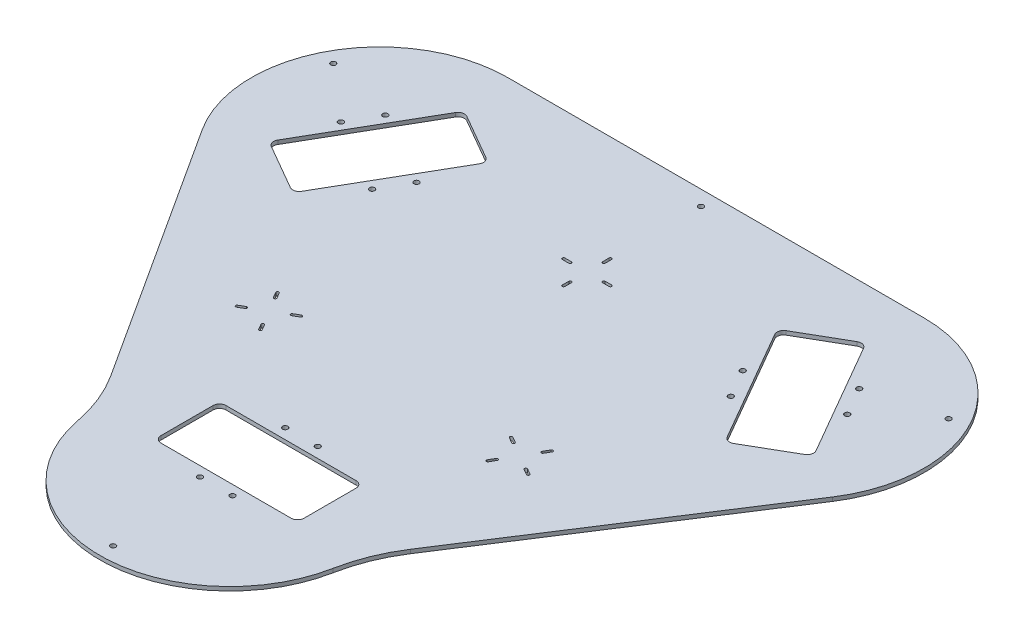
from build123d import *

# Parameters (mm, degrees)
SKETCH2_R           = 2
BOSS_EXTRUDE1_DEPTH = 3
SKETCH5_R           = 2
CUT_EXTRUDE3_DEPTH  = 92
CUT_EXTRUDE5_DEPTH  = 10


with BuildPart() as part:
    # Sketch2 → Boss-Extrude1 (new body)
    with BuildSketch(Plane(origin=(0, 0, 0), x_dir=(1, 0, 0), z_dir=(0, 1, 0))):
        with BuildLine():
            Line((-242.852440467, 39.573874981), (-113.958962067, -159.70764714))
            ThreePointArc((-113.958962067, -159.70764714), (-103.371408315, -180.139975304), (-96.878813929, -202.217623429))
            ThreePointArc((-96.878813929, -202.217623429), (1.321917166, -283.333333333), (99.522648261, -202.217623429))
            ThreePointArc((99.522648261, -202.217623429), (106.015242647, -180.139975304), (116.6027964, -159.70764714))
            Line((116.6027964, -159.70764714), (244.060427664, 37.353919355))
            ThreePointArc((244.060427664, 37.353919355), (247.930993611, 139.46341826), (160.090354442, 191.668333333))
            Line((160.090354442, 191.668333333), (-160.090354442, 191.668333333))
            ThreePointArc((-160.090354442, 191.668333333), (-246.667324741, 140.214434267), (-242.852440467, 39.573874981))
        make_face()
        with Locations((-12.5, -192.545452)):
            Circle(SKETCH2_R, mode=Mode.SUBTRACT)
        with BuildLine():
            ThreePointArc((-55, -140), (-53.535533906, -136.464466094), (-50, -135))
            Line((-50, -135), (50, -135))
            ThreePointArc((50, -135), (53.535533906, -136.464466094), (55, -140))
            Line((55, -140), (55, -180))
            ThreePointArc((55, -180), (53.535533906, -183.535533906), (50, -185))
            Line((50, -185), (-50, -185))
            ThreePointArc((-50, -185), (-53.535533906, -183.535533906), (-55, -180))
            Line((-55, -180), (-55, -140))
        make_face(mode=Mode.SUBTRACT)
        with Locations((-12.5, -127)):
            Circle(SKETCH2_R, mode=Mode.SUBTRACT)
        with Locations((12.5, -192.545452)):
            Circle(SKETCH2_R, mode=Mode.SUBTRACT)
        with Locations((12.5, -127)):
            Circle(SKETCH2_R, mode=Mode.SUBTRACT)
        with Locations((-137.885861375, 65.174682453)):
            Circle(SKETCH2_R, mode=Mode.SUBTRACT)
        with Locations((-194.64988791, 97.947408453)):
            Circle(SKETCH2_R, mode=Mode.SUBTRACT)
        with BuildLine():
            Line((-113.564064606, 123.301270189), (-138.564064606, 80))
            Line((-138.564064606, 80), (-163.564064606, 36.698729811))
            ThreePointArc((-163.564064606, 36.698729811), (-166.600096399, 34.369100679), (-170.394191624, 34.868602792))
            Line((-170.394191624, 34.868602792), (-205.035207776, 54.868602792))
            ThreePointArc((-205.035207776, 54.868602792), (-207.364836907, 57.904634585), (-206.865334795, 61.698729811))
            Line((-206.865334795, 61.698729811), (-156.865334795, 148.301270189))
            ThreePointArc((-156.865334795, 148.301270189), (-153.829303001, 150.630899321), (-150.035207776, 150.131397208))
            Line((-150.035207776, 150.131397208), (-115.394191624, 130.131397208))
            ThreePointArc((-115.394191624, 130.131397208), (-113.064562493, 127.095365415), (-113.564064606, 123.301270189))
        make_face(mode=Mode.SUBTRACT)
        with Locations((-182.14988791, 119.598043547)):
            Circle(SKETCH2_R, mode=Mode.SUBTRACT)
        with Locations((-125.385861375, 86.825317547)):
            Circle(SKETCH2_R, mode=Mode.SUBTRACT)
        with Locations((137.885861375, 65.174682453)):
            Circle(SKETCH2_R, mode=Mode.SUBTRACT)
        with Locations((125.385861375, 86.825317547)):
            Circle(SKETCH2_R, mode=Mode.SUBTRACT)
        with BuildLine():
            Line((163.564064606, 36.698729811), (138.564064606, 80))
            Line((138.564064606, 80), (113.564064606, 123.301270189))
            ThreePointArc((113.564064606, 123.301270189), (113.064562493, 127.095365415), (115.394191624, 130.131397208))
            Line((115.394191624, 130.131397208), (150.035207776, 150.131397208))
            ThreePointArc((150.035207776, 150.131397208), (153.829303001, 150.630899321), (156.865334795, 148.301270189))
            Line((156.865334795, 148.301270189), (206.865334795, 61.698729811))
            ThreePointArc((206.865334795, 61.698729811), (207.364836907, 57.904634585), (205.035207776, 54.868602792))
            Line((205.035207776, 54.868602792), (187.7146997, 44.868602792))
            Line((187.7146997, 44.868602792), (170.394191624, 34.868602792))
            ThreePointArc((170.394191624, 34.868602792), (166.600096399, 34.369100679), (163.564064606, 36.698729811))
        make_face(mode=Mode.SUBTRACT)
        with Locations((194.64988791, 97.947408453)):
            Circle(SKETCH2_R, mode=Mode.SUBTRACT)
        with Locations((182.14988791, 119.598043547)):
            Circle(SKETCH2_R, mode=Mode.SUBTRACT)
    extrude(amount=BOSS_EXTRUDE1_DEPTH)

    # Sketch5 → Cut-Extrude3 (cut)
    with BuildSketch(Plane(origin=(0, 3, 0), x_dir=(1, 0, 0), z_dir=(0, 1, 0))):
        with Locations((0, 180.168332775)):
            Circle(SKETCH5_R)
        with Locations((236.5079546, 133.966482848)):
            Circle(SKETCH5_R)
        with Locations((-236.507954462, 133.966482869)):
            Circle(SKETCH5_R)
        with Locations((0, -271.833334923)):
            Circle(SKETCH5_R)
    extrude(amount=-CUT_EXTRUDE3_DEPTH, mode=Mode.SUBTRACT)

    # Sketch7 → Cut-Extrude5 (cut)
    with BuildSketch(Plane(origin=(0, 3, 0), x_dir=(1, 0, 0), z_dir=(0, 1, 0))):
        with BuildLine():
            Line((-1, 110.502325279), (-1, 105.502325279))
            ThreePointArc((-1, 105.502325279), (0, 104.502325279), (1, 105.502325279))
            Line((1, 105.502325279), (1, 110.502325279))
            ThreePointArc((1, 110.502325279), (0, 111.502325279), (-1, 110.502325279))
        make_face()
        with BuildLine():
            Line((-106.234238689, -40.545808051), (-103.734238689, -44.87593507))
            ThreePointArc((-103.734238689, -44.87593507), (-102.368213267, -45.241960479), (-102.002187858, -43.875935056))
            Line((-102.002187858, -43.875935056), (-104.502187858, -39.545808037))
            ThreePointArc((-104.502187858, -39.545808037), (-105.86821328, -39.179782628), (-106.234238689, -40.545808051))
        make_face()
        with BuildLine():
            Line((112.469526392, -63.7796108), (108.139399373, -61.2796108))
            ThreePointArc((108.139399373, -61.2796108), (106.773373969, -61.645636204), (107.139399373, -63.011661607))
            Line((107.139399373, -63.011661607), (111.469526392, -65.511661607))
            ThreePointArc((111.469526392, -65.511661607), (112.835551796, -65.145636204), (112.469526392, -63.7796108))
        make_face()
        with BuildLine():
            Line((85.622738875, -48.2796108), (81.292611856, -45.7796108))
            ThreePointArc((81.292611856, -45.7796108), (79.926586452, -46.145636204), (80.292611856, -47.511661607))
            Line((80.292611856, -47.511661607), (84.622738875, -50.011661607))
            ThreePointArc((84.622738875, -50.011661607), (85.988764279, -49.645636204), (85.622738875, -48.2796108))
        make_face()
        with BuildLine():
            Line((88.247094528, -71.734093472), (90.747094528, -67.403966453))
            ThreePointArc((90.747094528, -67.403966453), (90.381069124, -66.037941049), (89.01504372, -66.403966453))
            Line((89.01504372, -66.403966453), (86.51504372, -70.734093472))
            ThreePointArc((86.51504372, -70.734093472), (86.881069124, -72.100118875), (88.247094528, -71.734093472))
        make_face()
        with BuildLine():
            ThreePointArc((102.01504372, -43.887305954), (102.381069124, -45.253331358), (103.747094528, -44.887305954))
            Line((103.747094528, -44.887305954), (106.247094528, -40.557178935))
            ThreePointArc((106.247094528, -40.557178935), (105.881069124, -39.191153532), (104.51504372, -39.557178935))
            Line((104.51504372, -39.557178935), (102.01504372, -43.887305954))
        make_face()
        with BuildLine():
            ThreePointArc((-89.00218787, -66.392595562), (-90.368213274, -66.026570158), (-90.734238677, -67.392595562))
            Line((-90.734238677, -67.392595562), (-88.234238677, -71.72272258))
            ThreePointArc((-88.234238677, -71.72272258), (-86.868213274, -72.088747984), (-86.50218787, -70.72272258))
            Line((-86.50218787, -70.72272258), (-89.00218787, -66.392595562))
        make_face()
        with BuildLine():
            Line((-81.279756017, -45.768239915), (-85.609883036, -48.268239915))
            ThreePointArc((-85.609883036, -48.268239915), (-85.97590844, -49.634265319), (-84.609883036, -50.000290723))
            Line((-84.609883036, -50.000290723), (-80.279756017, -47.500290723))
            ThreePointArc((-80.279756017, -47.500290723), (-79.913730614, -46.134265319), (-81.279756017, -45.768239915))
        make_face()
        with BuildLine():
            ThreePointArc((-107.126543535, -63.000290723), (-106.760518131, -61.634265319), (-108.126543535, -61.268239915))
            Line((-108.126543535, -61.268239915), (-112.456670554, -63.768239915))
            ThreePointArc((-112.456670554, -63.768239915), (-112.822695957, -65.134265319), (-111.456670554, -65.500290723))
            Line((-111.456670554, -65.500290723), (-107.126543535, -63.000290723))
        make_face()
        with BuildLine():
            ThreePointArc((1, 79.502325279), (0, 80.502325279), (-1, 79.502325279))
            Line((-1, 79.502325279), (-1, 74.502325279))
            ThreePointArc((-1, 74.502325279), (0, 73.502325279), (1, 74.502325279))
            Line((1, 74.502325279), (1, 79.502325279))
        make_face()
        with BuildLine():
            Line((18, 93.502325279), (13, 93.502325279))
            ThreePointArc((13, 93.502325279), (12, 92.502325279), (13, 91.502325279))
            Line((13, 91.502325279), (18, 91.502325279))
            ThreePointArc((18, 91.502325279), (19, 92.502325279), (18, 93.502325279))
        make_face()
        with BuildLine():
            ThreePointArc((-13, 91.502325279), (-12, 92.502325279), (-13, 93.502325279))
            Line((-13, 93.502325279), (-18, 93.502325279))
            ThreePointArc((-18, 93.502325279), (-19, 92.502325279), (-18, 91.502325279))
            Line((-18, 91.502325279), (-13, 91.502325279))
        make_face()
    extrude(amount=-CUT_EXTRUDE5_DEPTH, mode=Mode.SUBTRACT)


solid = part.part
